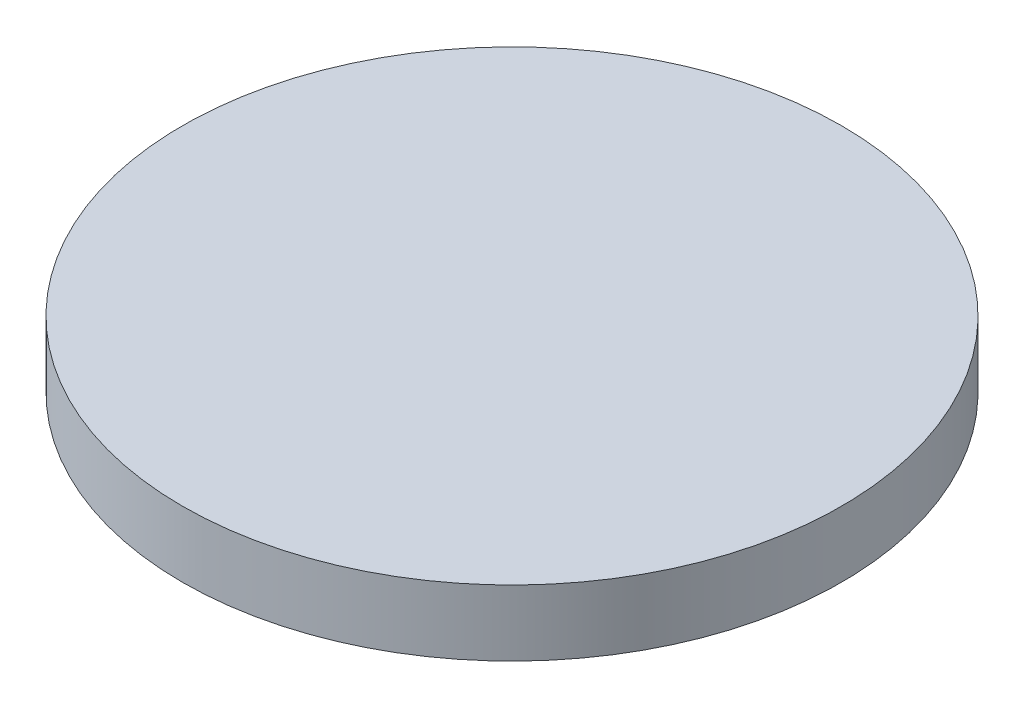
from build123d import *

# Parameters (mm, degrees)
ESQUISSE1_R      = 50
EXTRUSION1_DEPTH = 10


with BuildPart() as part:
    # Esquisse1 → Extrusion1 (new body)
    with BuildSketch(Plane(origin=(0, 0, 0), x_dir=(1, 0, 0), z_dir=(0, 1, 0))):
        Circle(ESQUISSE1_R)
    extrude(amount=EXTRUSION1_DEPTH)


solid = part.part
